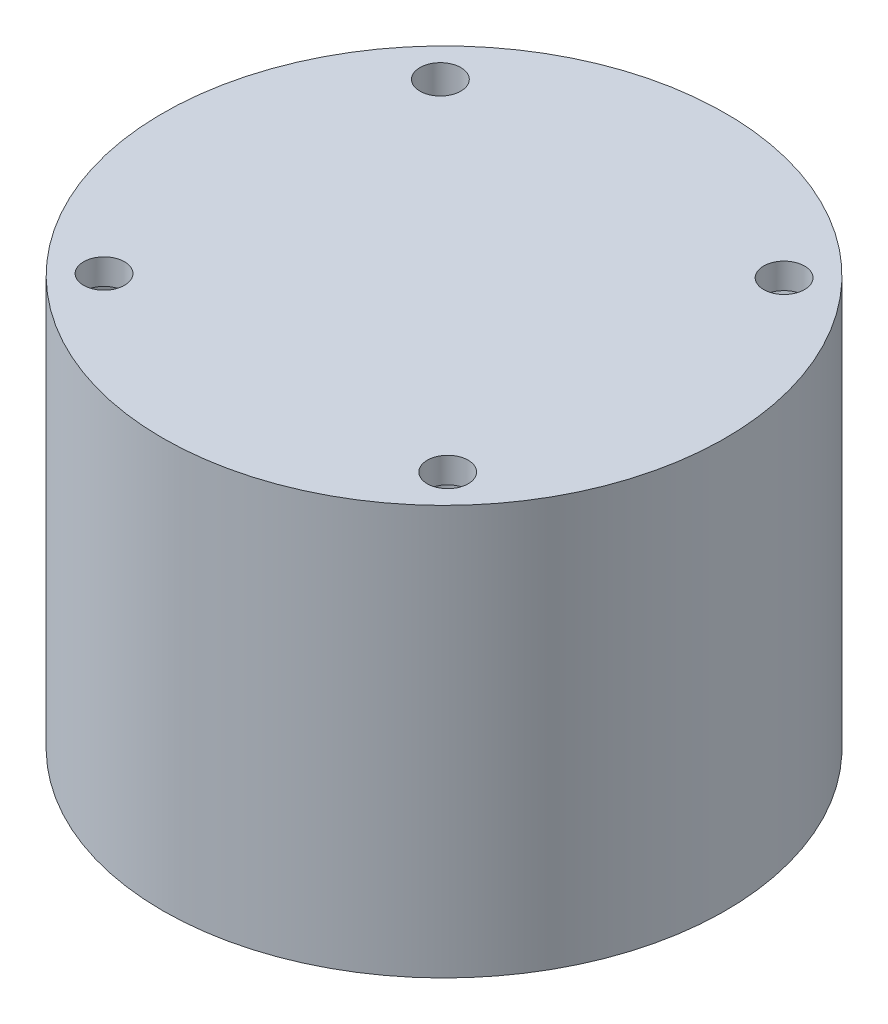
from build123d import *

# Parameters (mm, degrees)
SKETCH_1_R          = 55
EXTRUDE_1_DEPTH     = 80
SKETCH_2_R          = 50
CUT_EXTRUDE_1_DEPTH = 75
SKETCH_3_W          = 33.5
SKETCH_3_H          = 15
CUT_EXTRUDE_2_DEPTH = 6
SKETCH_4_R          = 4
CUT_EXTRUDE_3_DEPTH = 81
SKETCH2_W           = 33.5
SKETCH2_H           = 15
BOSS_EXTRUDE1_DEPTH = 5


with BuildPart() as part:
    # Эскиз1 → Бобышка-Вытянуть1 (new body)
    with BuildSketch(Plane(origin=(0, 0, 0), x_dir=(1, 0, 0), z_dir=(0, 1, 0))):
        Circle(SKETCH_1_R)
    extrude(amount=EXTRUDE_1_DEPTH)

    # Эскиз2 → Вырез-Вытянуть1 (cut)
    with BuildSketch(Plane.XZ):
        Circle(SKETCH_2_R)
    extrude(amount=-CUT_EXTRUDE_1_DEPTH, mode=Mode.SUBTRACT)

    # Эскиз3 → Вырез-Вытянуть2 (cut, through all)
    with BuildSketch(Plane.XZ.offset(-75)):
        Rectangle(SKETCH_3_W, SKETCH_3_H)
    extrude(amount=-CUT_EXTRUDE_2_DEPTH, mode=Mode.SUBTRACT)

    # Эскиз4 → Вырез-Вытянуть3 (cut, through all)
    with BuildSketch(Plane(origin=(0, 80, 0), x_dir=(1, 0, 0), z_dir=(0, 1, 0))):
        with Locations((33.591727056, -32.872418125)):
            Circle(SKETCH_4_R)
        with Locations((-33.591727056, -32.872418125)):
            Circle(SKETCH_4_R)
        with Locations((-33.591727056, 32.872418125)):
            Circle(SKETCH_4_R)
        with Locations((33.591727056, 32.872418125)):
            Circle(SKETCH_4_R)
    extrude(amount=-CUT_EXTRUDE_3_DEPTH, mode=Mode.SUBTRACT)

    # Sketch2 → Boss-Extrude1 (add)
    with BuildSketch(Plane(origin=(0, 80, 0), x_dir=(1, 0, 0), z_dir=(0, 1, 0))):
        Rectangle(SKETCH2_W, SKETCH2_H)
    extrude(amount=-BOSS_EXTRUDE1_DEPTH)


solid = part.part
